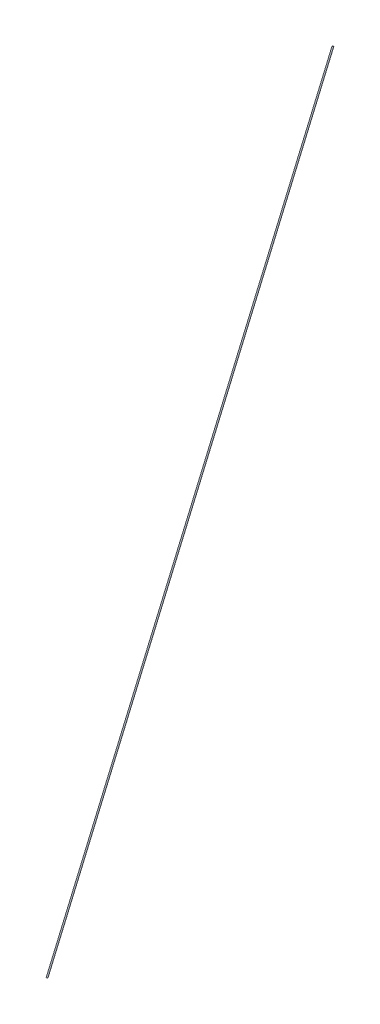
from build123d import *

# Parameters (mm, degrees)
SWEEP_2_PROFILE_R = 0.5


with BuildPart() as part:
    # 扫描2: sweep along a path in 草图3
    with BuildLine(Plane(origin=(0, 0, 0), x_dir=(0, 0, -1), z_dir=(1, 0, 0))) as sweep_2_path:
        Line((0, 505), (-217.5, 0))
    # 扫描2 profile (on start of the path) → 扫描2 (sweep)
    with BuildSketch(Plane(origin=(0, 505, 0), x_dir=(0, -0.395564894, -0.91843803), z_dir=(0, -0.91843803, 0.395564894))):
        Circle(SWEEP_2_PROFILE_R)
    sweep(path=sweep_2_path.line)


solid = part.part
